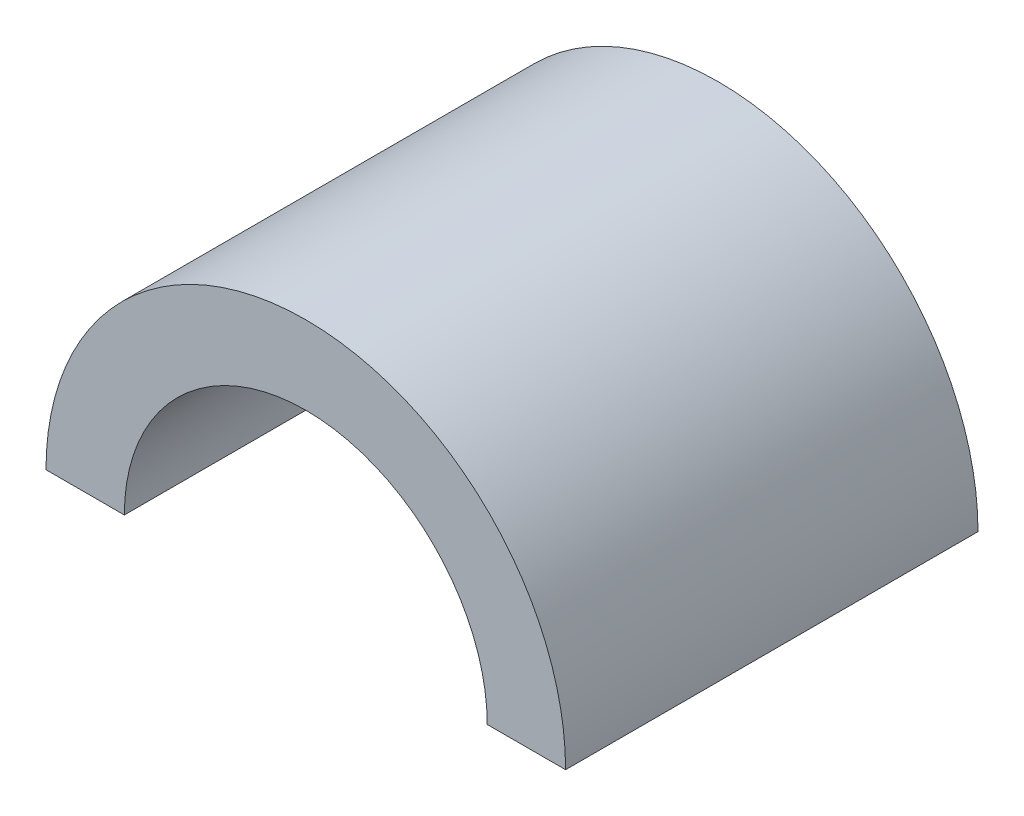
from build123d import *

# Parameters (mm, degrees)
BOSS_EXTRUDE1_DEPTH = 25.4


with BuildPart() as part:
    # Sketch1 → Boss-Extrude1 (new body)
    with BuildSketch(Plane.XY):
        with BuildLine():
            Line((-16.002, 0), (-11.176, 0))
            ThreePointArc((-11.176, 0), (0, 11.176), (11.176, 0))
            Line((11.176, 0), (16.002, 0))
            ThreePointArc((16.002, 0), (0, 16.002), (-16.002, 0))
        make_face()
    extrude(amount=BOSS_EXTRUDE1_DEPTH)


solid = part.part
